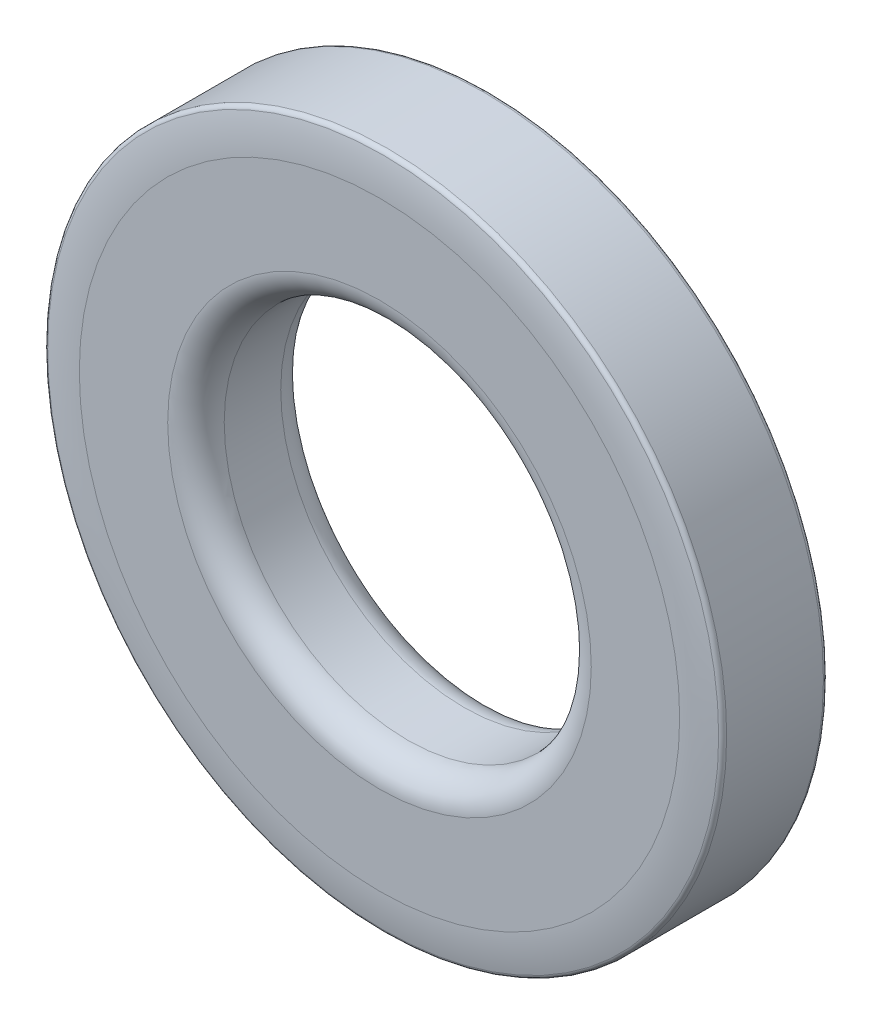
from build123d import *

# Parameters (mm, degrees)
SKETCH3_R           = 9.525
SKETCH3_R_2         = 5.1562
BOSS_EXTRUDE1_DEPTH = 1.5875
FILLET1_R           = 0.127


with BuildPart() as part:
    # Sketch3 → Boss-Extrude1 (new, symmetric)
    with BuildSketch(Plane.XY):
        Circle(SKETCH3_R)
        Circle(SKETCH3_R_2, mode=Mode.SUBTRACT)
    extrude(amount=BOSS_EXTRUDE1_DEPTH, both=True)

    # Sketch4 → Cut-Revolve1 (revolve, cut)
    with BuildSketch(Plane(origin=(0, 0, 0), x_dir=(0, 0, -1), z_dir=(1, 0, 0)), mode=Mode.PRIVATE) as cut_revolve1_sk:
        with BuildLine():
            Line((-1.4605, 9.525), (-1.5875, 9.525))
            Line((-1.5875, 9.525), (-1.5875, 8.4328))
            ThreePointArc((-1.5875, 8.4328), (-1.555643398, 8.982579465), (-1.4605, 9.525))
        make_face()
        with BuildLine():
            Line((-0.79375, 5.1562), (-1.5875, 5.1562))
            Line((-1.5875, 5.1562), (-1.5875, 5.94995))
            ThreePointArc((-1.5875, 5.94995), (-1.355016008, 5.388683992), (-0.79375, 5.1562))
        make_face()
    cut_revolve1 = revolve(cut_revolve1_sk.sketch.rotate(Axis((0, 0, 1.5875), (0, 0, -1)), 180), axis=Axis((0, 0, 1.5875), (0, 0, -1)), mode=Mode.SUBTRACT)

    # Mirror1: Cut-Revolve1 across plane
    add(cut_revolve1.mirror(Plane.XY), mode=Mode.SUBTRACT)

    # Fillet1
    fillet1_edges = [part.edges().sort_by_distance(p)[0] for p in [
        (-6.735192091, 6.735192091, 1.4605),
        (6.735192091, -6.735192091, -1.4605),
    ]]
    fillet(fillet1_edges, radius=FILLET1_R)


solid = part.part
